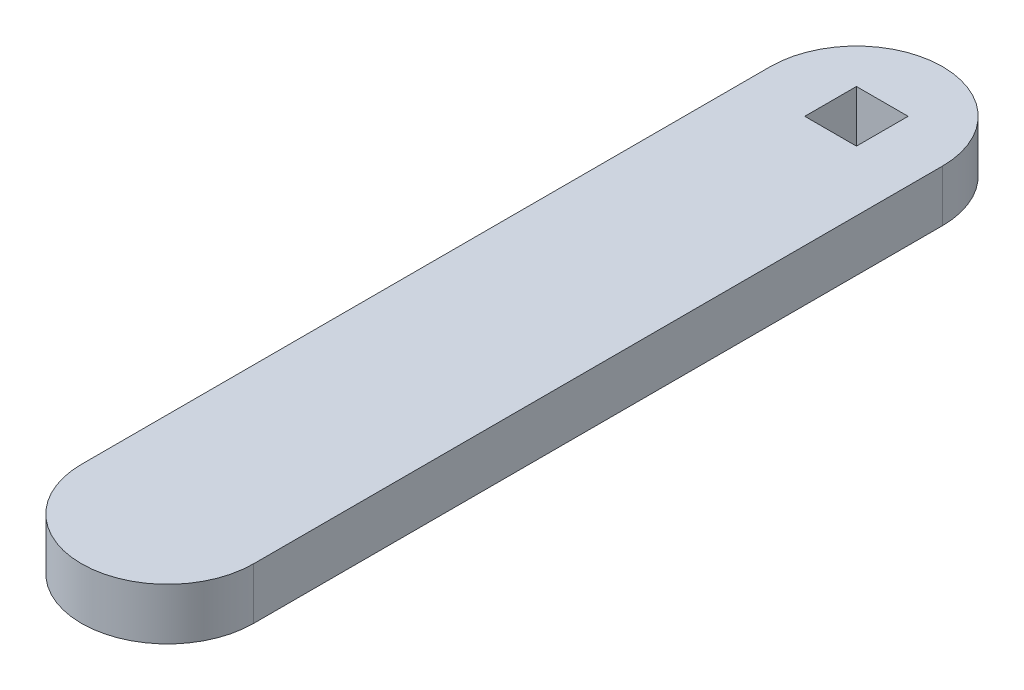
from build123d import *

# Parameters (mm, degrees)
EXTRUDE_1_DEPTH     = 30
SKETCH_2_W          = 30
SKETCH_2_H          = 30
CUT_EXTRUDE_1_DEPTH = 31


with BuildPart() as part:
    # 草图1 → 凸台-拉伸1 (new body)
    with BuildSketch(Plane(origin=(0, 0, 0), x_dir=(1, 0, 0), z_dir=(0, 1, 0))):
        with BuildLine():
            Line((50, 200), (50, -200))
            ThreePointArc((50, -200), (0, -250), (-50, -200))
            Line((-50, -200), (-50, 200))
            ThreePointArc((-50, 200), (0, 250), (50, 200))
        make_face()
    extrude(amount=EXTRUDE_1_DEPTH)

    # 草图2 → 切除-拉伸1 (cut, through all)
    with BuildSketch(Plane(origin=(0, 30, 0), x_dir=(1, 0, 0), z_dir=(0, 1, 0))):
        with Locations((0, 200)):
            Rectangle(SKETCH_2_W, SKETCH_2_H)
    extrude(amount=-CUT_EXTRUDE_1_DEPTH, mode=Mode.SUBTRACT)


solid = part.part
